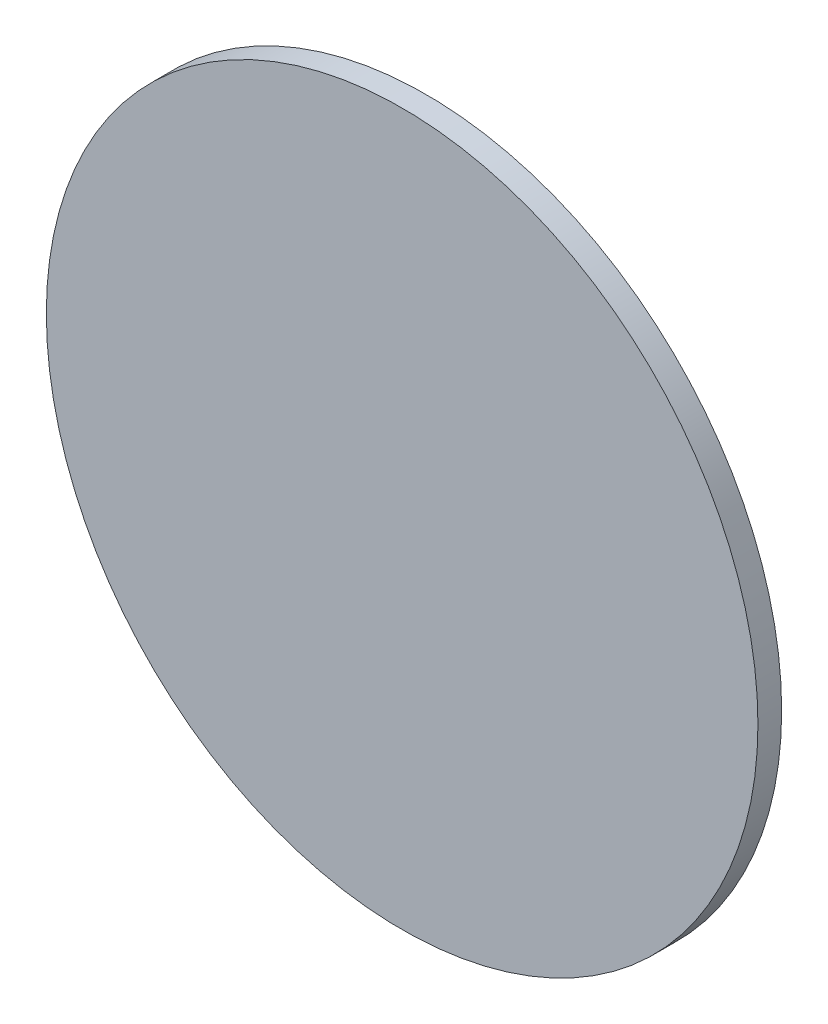
from build123d import *

# Parameters (mm, degrees)
SKETCH1_R           = 38.1
BOSS_EXTRUDE1_DEPTH = 2.54


with BuildPart() as part:
    # Sketch1 → Boss-Extrude1 (new body)
    with BuildSketch(Plane.XY):
        Circle(SKETCH1_R)
    extrude(amount=BOSS_EXTRUDE1_DEPTH)


solid = part.part
